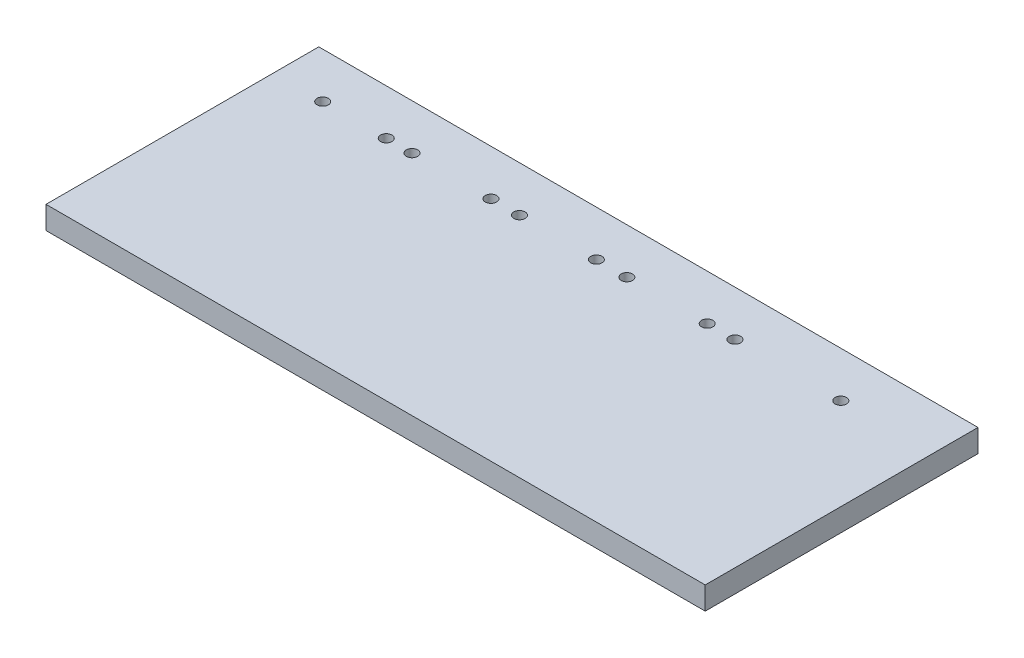
from build123d import *

# Parameters (mm, degrees)
SKETCH_1_W          = 290
SKETCH_1_H          = 120
EXTRUDE_1_DEPTH     = 10
SKETCH_2_R          = 2.5
CUT_EXTRUDE_1_DEPTH = 11


with BuildPart() as part:
    # Эскиз1 → Бобышка-Вытянуть1 (new body)
    with BuildSketch(Plane(origin=(0, 0, 0), x_dir=(1, 0, 0), z_dir=(0, 1, 0))):
        with Locations((145, 60)):
            Rectangle(SKETCH_1_W, SKETCH_1_H)
    extrude(amount=EXTRUDE_1_DEPTH)

    # Эскиз2 → Вырез-Вытянуть1 (cut, through all)
    with BuildSketch(Plane(origin=(0, 10, 0), x_dir=(1, 0, 0), z_dir=(0, 1, 0))):
        with Locations((203.059493975, 100)):
            Circle(SKETCH_2_R)
        with Locations((155.543798527, 100)):
            Circle(SKETCH_2_R)
        with Locations((108.276640676, 100)):
            Circle(SKETCH_2_R)
        with Locations((61.009482825, 100)):
            Circle(SKETCH_2_R)
        with Locations((21.729032917, 100)):
            Circle(SKETCH_2_R)
        with Locations((49.683486534, 100)):
            Circle(SKETCH_2_R)
        with Locations((95.742538115, 100)):
            Circle(SKETCH_2_R)
        with Locations((142.103616263, 100)):
            Circle(SKETCH_2_R)
        with Locations((190.880906953, 100)):
            Circle(SKETCH_2_R)
        with Locations((249.655647954, 100)):
            Circle(SKETCH_2_R)
    extrude(amount=-CUT_EXTRUDE_1_DEPTH, mode=Mode.SUBTRACT)


solid = part.part
